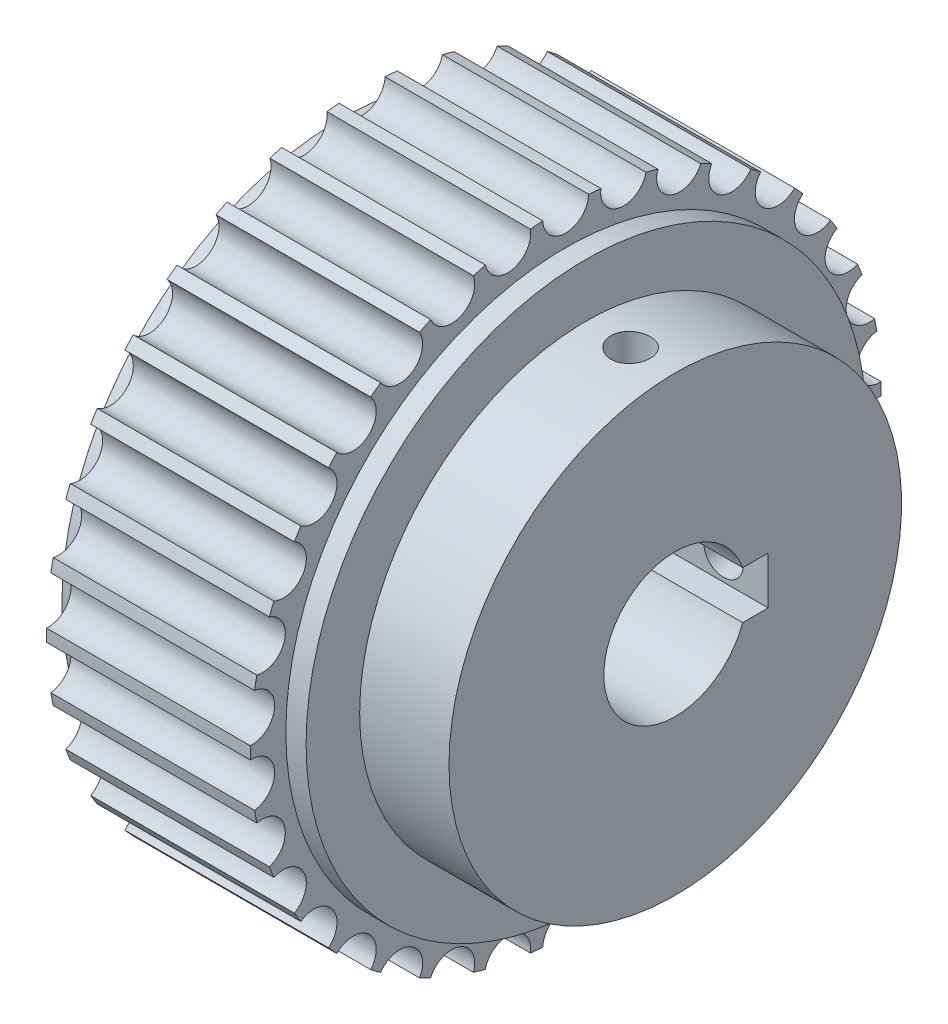
from build123d import *

# Parameters (mm, degrees)
SKETCH2_R          = 1.93
CUT_EXTRUDE1_DEPTH = 27.3
CIRPATTERN1_COUNT  = 34
SKETCH6_W          = 1.65
SKETCH6_H          = 19.001
CIRPATTERN2_COUNT  = 2
CIRPATTERN2_ANGLE  = 90
SKETCH8_W          = 3.6
SKETCH8_H          = 4
CUT_EXTRUDE2_DEPTH = 29.0000001
SKETCH9_R          = 16.5
CUT_EXTRUDE3_DEPTH = 5.7


with BuildPart() as part:
    # Sketch1 → Revolve1 (revolve)
    with BuildSketch(Plane.XY):
        Polygon((-10.25, 6), (17.75, 6), (17.75, 19), (10.25, 19), (10.25, 23.5), (8.55, 23.5), (8.55, 26.485), (-8.55, 26.485), (-8.55, 23.5), (-10.25, 23.5), align=None)
    revolve(axis=Axis((0, 0, 0), (1, 0, 0)))

    # Sketch2 → Cut-Extrude1 (cut, through all)
    with BuildSketch(Plane.ZY.offset(8.55)):
        with Locations((0, 26.485)):
            Circle(SKETCH2_R)
    cut_extrude1 = extrude(amount=-CUT_EXTRUDE1_DEPTH, mode=Mode.SUBTRACT)

    # CirPattern1: Cut-Extrude1 ×34 about axis
    cirpattern1_axis = Axis((0, 0, 0), (1, 0, 0))
    for i in range(1, CIRPATTERN1_COUNT):
        add(cut_extrude1.rotate(cirpattern1_axis, i * 360 / CIRPATTERN1_COUNT), mode=Mode.SUBTRACT)

    # Sketch6 → M4x0.7 Tapped Hole1 (revolve, cut)
    with BuildSketch(Plane(origin=(14, 0, 0), x_dir=(0, 0, -1), z_dir=(1, 0, 0))):
        with Locations((0.825, 9.5005)):
            Rectangle(SKETCH6_W, SKETCH6_H)
    m4x0_7_tapped_hole1 = revolve(axis=Axis((14, -6.35, 0), (0, 1, 0)), mode=Mode.SUBTRACT)

    # CirPattern2: M4x0.7 Tapped Hole1 ×2 about axis
    cirpattern2_axis = Axis((0, 0, 0), (-1, 0, 0))
    for i in range(1, CIRPATTERN2_COUNT):
        add(m4x0_7_tapped_hole1.rotate(cirpattern2_axis, i * CIRPATTERN2_ANGLE / (CIRPATTERN2_COUNT - 1)), mode=Mode.SUBTRACT)

    # Sketch8 → Cut-Extrude2 (cut, through all)
    with BuildSketch(Plane(origin=(17.75, 0, 0), x_dir=(0, 0, -1), z_dir=(1, 0, 0))):
        with Locations((6, 0)):
            Rectangle(SKETCH8_W, SKETCH8_H)
    extrude(amount=-CUT_EXTRUDE2_DEPTH, mode=Mode.SUBTRACT)

    # Sketch9 → Cut-Extrude3 (cut)
    with BuildSketch(Plane.ZY.offset(10.25)):
        Circle(SKETCH9_R)
    extrude(amount=-CUT_EXTRUDE3_DEPTH, mode=Mode.SUBTRACT)


solid = part.part
